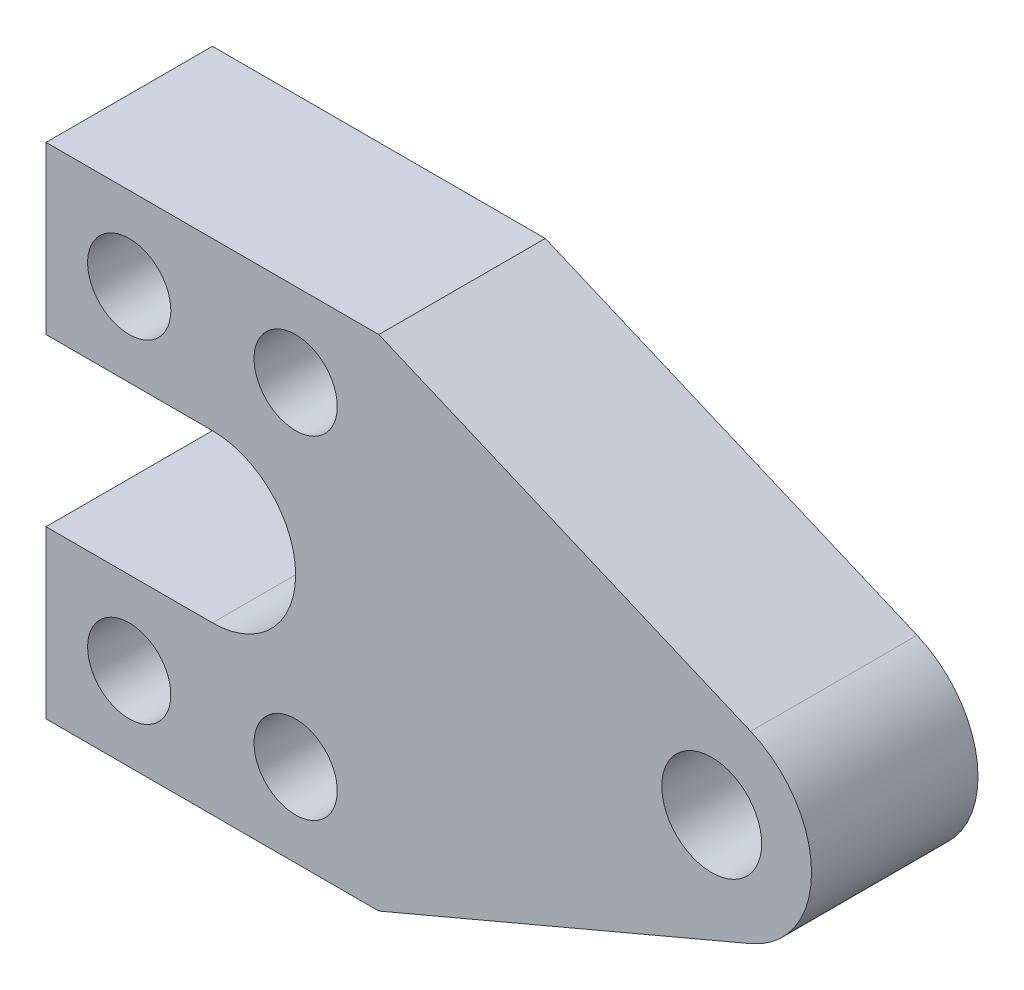
from build123d import *

# Parameters (mm, degrees)
SKETCH1_R           = 6
SKETCH1_R_2         = 5
BOSS_EXTRUDE1_DEPTH = 20


with BuildPart() as part:
    # Sketch1 → Boss-Extrude1 (new body)
    with BuildSketch(Plane.XY):
        with BuildLine():
            Line((0, 10), (20, 10))
            ThreePointArc((20, 10), (30, 0), (20, -10))
            Line((20, -10), (0, -10))
            Line((0, -10), (0, -30))
            Line((0, -30), (40, -30))
            Line((40, -30), (84.685564793, -11.047419724))
            ThreePointArc((84.685564793, -11.047419724), (92, 0), (84.685564793, 11.047419724))
            Line((84.685564793, 11.047419724), (40, 30))
            Line((40, 30), (0, 30))
            Line((0, 30), (0, 10))
        make_face()
        with Locations((80, 0)):
            Circle(SKETCH1_R, mode=Mode.SUBTRACT)
        with Locations((10, 20)):
            Circle(SKETCH1_R_2, mode=Mode.SUBTRACT)
        with Locations((30, 20)):
            Circle(SKETCH1_R_2, mode=Mode.SUBTRACT)
        with Locations((30, -20)):
            Circle(SKETCH1_R_2, mode=Mode.SUBTRACT)
        with Locations((10, -20)):
            Circle(SKETCH1_R_2, mode=Mode.SUBTRACT)
    extrude(amount=BOSS_EXTRUDE1_DEPTH)


solid = part.part
